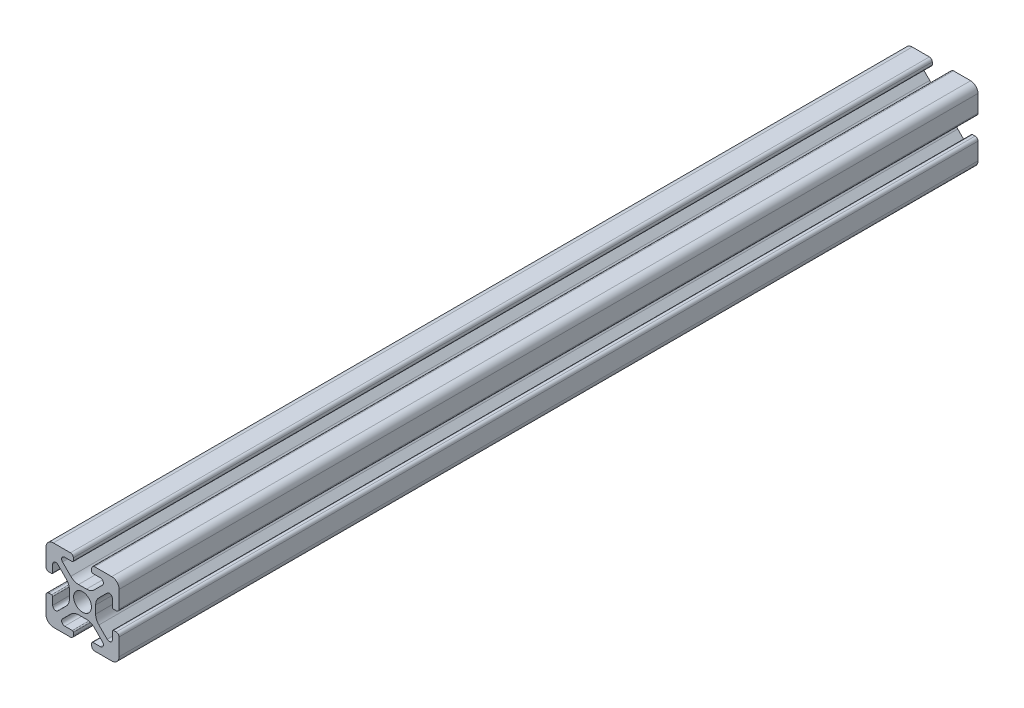
from build123d import *

# Parameters (mm, degrees)
SKETCH1_R           = 2.44
BOSS_EXTRUDE1_DEPTH = 117.3


with BuildPart() as part:
    # Sketch1 → Boss-Extrude1 (new body, symmetric)
    with BuildSketch(Plane.XY):
        with BuildLine():
            Line((-9.98, 7.9734), (-9.98, 3.2974))
            ThreePointArc((-9.98, 3.2974), (-9.74937588, 2.74062412), (-9.1926, 2.51))
            Line((-9.1926, 2.51), (-8.4514, 2.51))
            ThreePointArc((-8.4514, 2.51), (-8.235873853, 2.599273853), (-8.1466, 2.8148))
            Line((-8.1466, 2.8148), (-8.1466, 4.87))
            ThreePointArc((-8.1466, 4.87), (-7.629165253, 5.644395824), (-6.715703096, 5.462696904))
            Line((-6.715703096, 5.462696904), (-4.460865747, 3.207859555))
            ThreePointArc((-4.460865747, 3.207859555), (-3.811154457, 2.235497894), (-3.583006192, 1.088519111))
            Line((-3.583006192, 1.088519111), (-3.583006192, -1.088519111))
            ThreePointArc((-3.583006192, -1.088519111), (-3.811154457, -2.235497894), (-4.460865747, -3.207859555))
            Line((-4.460865747, -3.207859555), (-6.715703096, -5.462696904))
            ThreePointArc((-6.715703096, -5.462696904), (-7.629165253, -5.644395824), (-8.1466, -4.87))
            Line((-8.1466, -4.87), (-8.1466, -2.8148))
            ThreePointArc((-8.1466, -2.8148), (-8.235873853, -2.599273853), (-8.4514, -2.51))
            Line((-8.4514, -2.51), (-9.1926, -2.51))
            ThreePointArc((-9.1926, -2.51), (-9.74937588, -2.74062412), (-9.98, -3.2974))
            Line((-9.98, -3.2974), (-9.98, -7.9734))
            ThreePointArc((-9.98, -7.9734), (-9.392280467, -9.392280467), (-7.9734, -9.98))
            Line((-7.9734, -9.98), (-3.2974, -9.98))
            ThreePointArc((-3.2974, -9.98), (-2.74062412, -9.74937588), (-2.51, -9.1926))
            Line((-2.51, -9.1926), (-2.51, -8.4514))
            ThreePointArc((-2.51, -8.4514), (-2.599273853, -8.235873853), (-2.8148, -8.1466))
            Line((-2.8148, -8.1466), (-4.87, -8.1466))
            ThreePointArc((-4.87, -8.1466), (-5.644395824, -7.629165253), (-5.462696904, -6.715703096))
            Line((-5.462696904, -6.715703096), (-3.207859555, -4.460865747))
            ThreePointArc((-3.207859555, -4.460865747), (-2.235497894, -3.811154457), (-1.088519111, -3.583006192))
            Line((-1.088519111, -3.583006192), (1.088519111, -3.583006192))
            ThreePointArc((1.088519111, -3.583006192), (2.235497894, -3.811154457), (3.207859555, -4.460865747))
            Line((3.207859555, -4.460865747), (5.462696904, -6.715703096))
            ThreePointArc((5.462696904, -6.715703096), (5.644395824, -7.629165253), (4.87, -8.1466))
            Line((4.87, -8.1466), (2.8148, -8.1466))
            ThreePointArc((2.8148, -8.1466), (2.599273853, -8.235873853), (2.51, -8.4514))
            Line((2.51, -8.4514), (2.51, -9.1926))
            ThreePointArc((2.51, -9.1926), (2.74062412, -9.74937588), (3.2974, -9.98))
            Line((3.2974, -9.98), (7.9734, -9.98))
            ThreePointArc((7.9734, -9.98), (9.392280467, -9.392280467), (9.98, -7.9734))
            Line((9.98, -7.9734), (9.98, -3.2974))
            ThreePointArc((9.98, -3.2974), (9.74937588, -2.74062412), (9.1926, -2.51))
            Line((9.1926, -2.51), (8.4514, -2.51))
            ThreePointArc((8.4514, -2.51), (8.235873853, -2.599273853), (8.1466, -2.8148))
            Line((8.1466, -2.8148), (8.1466, -4.87))
            ThreePointArc((8.1466, -4.87), (7.629165253, -5.644395824), (6.715703096, -5.462696904))
            Line((6.715703096, -5.462696904), (4.460865747, -3.207859555))
            ThreePointArc((4.460865747, -3.207859555), (3.811154457, -2.235497894), (3.583006192, -1.088519111))
            Line((3.583006192, -1.088519111), (3.583006192, 1.088519111))
            ThreePointArc((3.583006192, 1.088519111), (3.811154457, 2.235497894), (4.460865747, 3.207859555))
            Line((4.460865747, 3.207859555), (6.715703096, 5.462696904))
            ThreePointArc((6.715703096, 5.462696904), (7.629165253, 5.644395824), (8.1466, 4.87))
            Line((8.1466, 4.87), (8.1466, 2.8148))
            ThreePointArc((8.1466, 2.8148), (8.235873853, 2.599273853), (8.4514, 2.51))
            Line((8.4514, 2.51), (9.1926, 2.51))
            ThreePointArc((9.1926, 2.51), (9.74937588, 2.74062412), (9.98, 3.2974))
            Line((9.98, 3.2974), (9.98, 7.9734))
            ThreePointArc((9.98, 7.9734), (9.392280467, 9.392280467), (7.9734, 9.98))
            Line((7.9734, 9.98), (3.2974, 9.98))
            ThreePointArc((3.2974, 9.98), (2.74062412, 9.74937588), (2.51, 9.1926))
            Line((2.51, 9.1926), (2.51, 8.4514))
            ThreePointArc((2.51, 8.4514), (2.599273853, 8.235873853), (2.8148, 8.1466))
            Line((2.8148, 8.1466), (4.87, 8.1466))
            ThreePointArc((4.87, 8.1466), (5.644395824, 7.629165253), (5.462696904, 6.715703096))
            Line((5.462696904, 6.715703096), (3.207859555, 4.460865747))
            ThreePointArc((3.207859555, 4.460865747), (2.235497894, 3.811154457), (1.088519111, 3.583006192))
            Line((1.088519111, 3.583006192), (-1.088519111, 3.583006192))
            ThreePointArc((-1.088519111, 3.583006192), (-2.235497894, 3.811154457), (-3.207859555, 4.460865747))
            Line((-3.207859555, 4.460865747), (-5.462696904, 6.715703096))
            ThreePointArc((-5.462696904, 6.715703096), (-5.644395824, 7.629165253), (-4.87, 8.1466))
            Line((-4.87, 8.1466), (-2.8148, 8.1466))
            ThreePointArc((-2.8148, 8.1466), (-2.599273853, 8.235873853), (-2.51, 8.4514))
            Line((-2.51, 8.4514), (-2.51, 9.1926))
            ThreePointArc((-2.51, 9.1926), (-2.74062412, 9.74937588), (-3.2974, 9.98))
            Line((-3.2974, 9.98), (-7.9734, 9.98))
            ThreePointArc((-7.9734, 9.98), (-9.392280467, 9.392280467), (-9.98, 7.9734))
        make_face()
        Circle(SKETCH1_R, mode=Mode.SUBTRACT)
    extrude(amount=BOSS_EXTRUDE1_DEPTH, both=True)


solid = part.part
